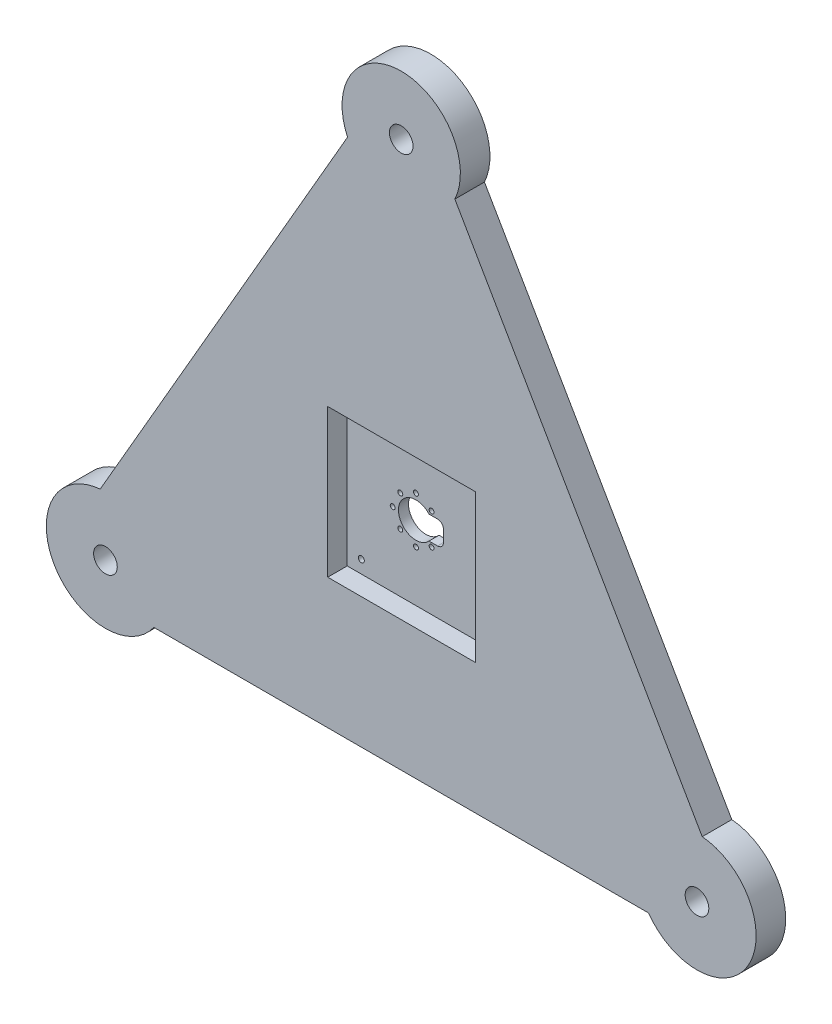
from build123d import *

# Parameters (mm, degrees)
BOSS_EXTRUDE9_DEPTH      = 12.7
SKETCH2_R                = 5.08
CUT_EXTRUDE1_DEPTH       = 1
CUT_EXTRUDE1_DEPTH_BACK  = 13.7
SKETCH4_R                = 5.08
CUT_EXTRUDE3_DEPTH       = 13.7
SKETCH6_W                = 63.5
SKETCH6_H                = 63.5
CUT_EXTRUDE10_DEPTH      = 8.382
SKETCH8_R                = 1.2954
CUT_EXTRUDE13_DEPTH      = 5.318
SKETCH20_R               = 1.045475937
SKETCH20_R_2             = 1.05
SKETCH20_R_3             = 1.053113333
SKETCH20_R_4             = 1.049702702
SKETCH20_R_5             = 1.060351353
SKETCH20_R_6             = 1.041366857
CUT_EXTRUDE14_DEPTH      = 5.318
SKETCH22_R               = 7.507138663
CUT_EXTRUDE15_DEPTH      = 12.742239248
SKETCH26_R               = 5.08
CUT_EXTRUDE16_DEPTH      = 1
CUT_EXTRUDE16_DEPTH_BACK = 13.7


with BuildPart() as part:
    # Sketch1 → Boss-Extrude9 (new body)
    with BuildSketch(Plane.XY):
        with BuildLine():
            Line((129.25673796, -48.023936093), (23.038420334, 135.95158673))
            ThreePointArc((23.038420334, 135.95158673), (0, 172.046968374), (-23.038420334, 135.95158673))
            Line((-23.038420334, 135.95158673), (-129.25673796, -48.023936093))
            ThreePointArc((-129.25673796, -48.023936093), (-148.997045256, -86.023484187), (-106.218317626, -87.927650637))
            Line((-106.218317626, -87.927650637), (106.218317626, -87.927650637))
            ThreePointArc((106.218317626, -87.927650637), (148.997045256, -86.023484187), (129.25673796, -48.023936093))
        make_face()
        with BuildLine():
            ThreePointArc((-121.92, -73.323484187), (-131.399409051, -75.863484187), (-124.46, -68.924075136))
            Line((-124.46, -68.924075136), (-127, -73.323484187))
            Line((-127, -73.323484187), (-121.92, -73.323484187))
        make_face(mode=Mode.SUBTRACT)
        with BuildLine():
            ThreePointArc((124.46, -68.924075136), (131.399409051, -75.863484187), (121.92, -73.323484187))
            Line((121.92, -73.323484187), (127, -73.323484187))
            Line((127, -73.323484187), (124.46, -68.924075136))
        make_face(mode=Mode.SUBTRACT)
        with BuildLine():
            ThreePointArc((-2.54, 142.247559323), (0, 151.726968374), (2.54, 142.247559323))
            Line((2.54, 142.247559323), (0, 146.646968374))
            Line((0, 146.646968374), (-2.54, 142.247559323))
        make_face(mode=Mode.SUBTRACT)
    extrude(amount=BOSS_EXTRUDE9_DEPTH)

    # Sketch2 → Cut-Extrude1 (cut, two sides)
    with BuildSketch(Plane.XY.offset(12.7)) as cut_extrude1_sk:
        with Locations((127, -73.323484187)):
            Circle(SKETCH2_R)
    extrude(amount=CUT_EXTRUDE1_DEPTH, mode=Mode.SUBTRACT)
    extrude(cut_extrude1_sk.sketch, amount=-CUT_EXTRUDE1_DEPTH_BACK, mode=Mode.SUBTRACT)

    # Sketch4 → Cut-Extrude3 (cut, through all)
    with BuildSketch(Plane.XY.offset(12.7)):
        with Locations((0, 146.646968374)):
            Circle(SKETCH4_R)
    extrude(amount=-CUT_EXTRUDE3_DEPTH, mode=Mode.SUBTRACT)

    # Sketch6 → Cut-Extrude10 (cut)
    with BuildSketch(Plane.XY.offset(12.7)):
        with Locations((0.191375803, -0.191375803)):
            Rectangle(SKETCH6_W, SKETCH6_H)
    extrude(amount=-CUT_EXTRUDE10_DEPTH, mode=Mode.SUBTRACT)

    # Sketch8 → Cut-Extrude13 (cut, through all)
    with BuildSketch(Plane.XY.offset(4.318)):
        with Locations((-25.511301342, -26.409321294)):
            Circle(SKETCH8_R)
        with Locations((-25.511301342, 26.803242123)):
            Circle(SKETCH8_R)
        with Locations((27.230878657, 26.803242123)):
            Circle(SKETCH8_R)
        with Locations((27.230878657, -26.409321294)):
            Circle(SKETCH8_R)
    extrude(amount=-CUT_EXTRUDE13_DEPTH, mode=Mode.SUBTRACT)

    # Sketch20 → Cut-Extrude14 (cut, through all)
    with BuildSketch(Plane.XY.offset(4.318)):
        with Locations((4.671117374, 6.592866865)):
            Circle(SKETCH20_R)
        with Locations((-2.048882626, 9.872866865)):
            Circle(SKETCH20_R_2)
        with Locations((-8.768882626, 6.592866865)):
            Circle(SKETCH20_R_3)
        with Locations((-12.048882626, -0.127133135)):
            Circle(SKETCH20_R_4)
        with Locations((-2.048882626, -10.127133135)):
            Circle(SKETCH20_R_5)
        with Locations((-8.768882626, -6.847133135)):
            Circle(SKETCH20_R_2)
        with Locations((4.671117374, -6.847133135)):
            Circle(SKETCH20_R_6)
    extrude(amount=-CUT_EXTRUDE14_DEPTH, mode=Mode.SUBTRACT)

    # Sketch22 → Cut-Extrude15 (cut, through all)
    with BuildSketch(Plane.XY.offset(11.742239248)):
        with Locations((-2.054203471, -0.131892244)):
            Circle(SKETCH22_R)
        with BuildLine():
            Line((3.541287317, -5.127133135), (7.21512242, -5.127133135))
            ThreePointArc((7.21512242, -5.127133135), (9.011173644, -4.38318436), (9.75512242, -2.587133135))
            Line((9.75512242, -2.587133135), (9.75512242, 2.341072368))
            ThreePointArc((9.75512242, 2.341072368), (9.011173644, 4.137123592), (7.21512242, 4.881072368))
            Line((7.21512242, 4.881072368), (3.541287317, 4.881072368))
            Line((3.541287317, 4.881072368), (3.541287317, -5.127133135))
        make_face()
    extrude(amount=-CUT_EXTRUDE15_DEPTH, mode=Mode.SUBTRACT)

    # Sketch26 → Cut-Extrude16 (cut, two sides)
    with BuildSketch(Plane.XY.offset(12.7)) as cut_extrude16_sk:
        with Locations((-127, -73.323484187)):
            Circle(SKETCH26_R)
    extrude(amount=CUT_EXTRUDE16_DEPTH, mode=Mode.SUBTRACT)
    extrude(cut_extrude16_sk.sketch, amount=-CUT_EXTRUDE16_DEPTH_BACK, mode=Mode.SUBTRACT)


solid = part.part
